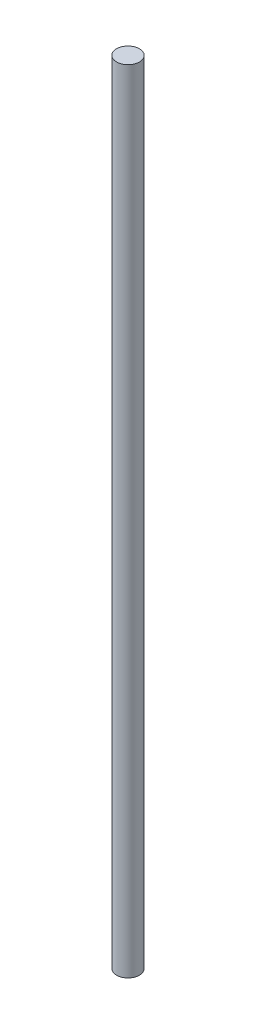
from build123d import *

# Parameters (mm, degrees)
SKETCH1_R = 0.94
ROD_DEPTH = 32.5


with BuildPart() as part:
    # Sketch1 → Rod (new body, symmetric)
    with BuildSketch(Plane(origin=(0, 0, 0), x_dir=(1, 0, 0), z_dir=(0, 1, 0))):
        Circle(SKETCH1_R)
    extrude(amount=ROD_DEPTH, both=True)


solid = part.part
